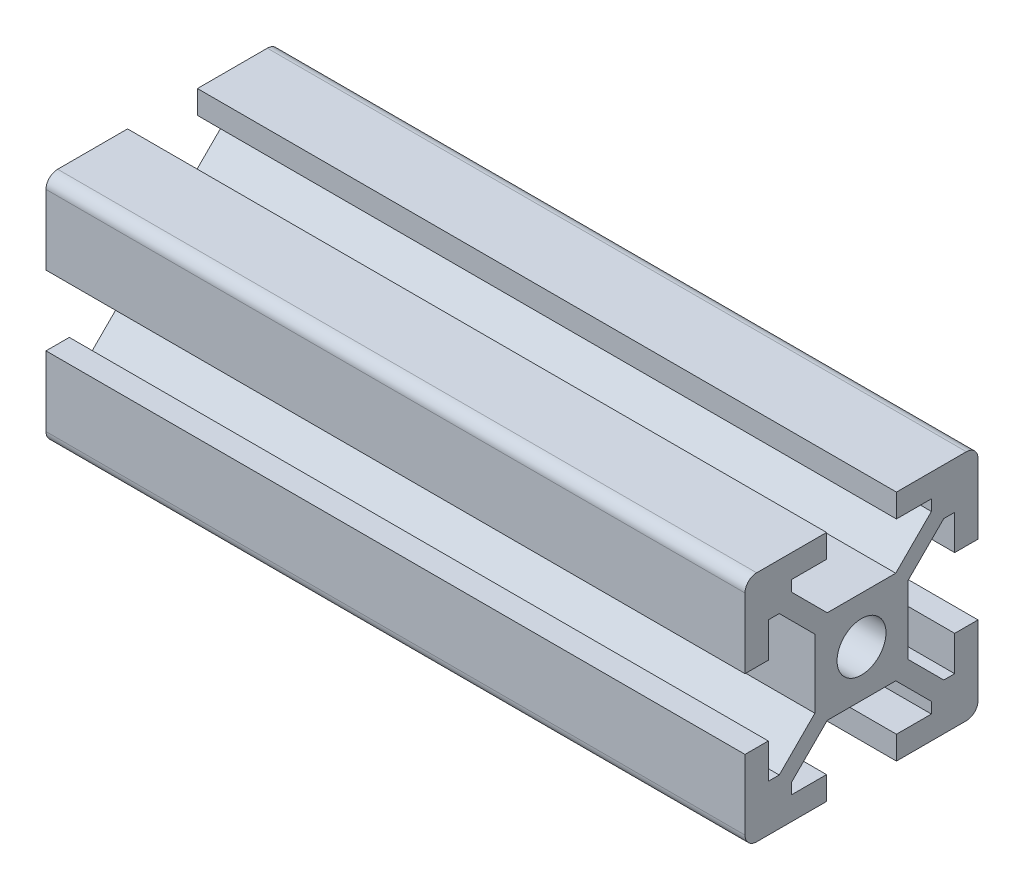
from build123d import *

# Parameters (mm, degrees)
SKETCH1_R           = 2.1
BOSS_EXTRUDE1_DEPTH = 60


with BuildPart() as part:
    # Sketch1 → Boss-Extrude1 (new body)
    with BuildSketch(Plane(origin=(0, 0, 0), x_dir=(0, 0, -1), z_dir=(1, 0, 0))):
        with BuildLine():
            Line((-10, 9), (-10, 3))
            Line((-10, 3), (-8, 3))
            Line((-8, 3), (-8, 6))
            Line((-8, 6), (-7.060660172, 6))
            Line((-7.060660172, 6), (-4, 2.939339828))
            Line((-4, 2.939339828), (-4, -2.939339828))
            Line((-4, -2.939339828), (-7.060660172, -6))
            Line((-7.060660172, -6), (-8, -6))
            Line((-8, -6), (-8, -3))
            Line((-8, -3), (-10, -3))
            Line((-10, -3), (-10, -9))
            ThreePointArc((-10, -9), (-9.707106781, -9.707106781), (-9, -10))
            Line((-9, -10), (-3, -10))
            Line((-3, -10), (-3, -8))
            Line((-3, -8), (-6, -8))
            Line((-6, -8), (-6, -7.060660172))
            Line((-6, -7.060660172), (-2.939339828, -4))
            Line((-2.939339828, -4), (2.939339828, -4))
            Line((2.939339828, -4), (6, -7.060660172))
            Line((6, -7.060660172), (6, -8))
            Line((6, -8), (3, -8))
            Line((3, -8), (3, -10))
            Line((3, -10), (9, -10))
            ThreePointArc((9, -10), (9.707106781, -9.707106781), (10, -9))
            Line((10, -9), (10, -3))
            Line((10, -3), (8, -3))
            Line((8, -3), (8, -6))
            Line((8, -6), (7.060660172, -6))
            Line((7.060660172, -6), (4, -2.939339828))
            Line((4, -2.939339828), (4, 2.939339828))
            Line((4, 2.939339828), (7.060660172, 6))
            Line((7.060660172, 6), (8, 6))
            Line((8, 6), (8, 3))
            Line((8, 3), (10, 3))
            Line((10, 3), (10, 9))
            ThreePointArc((10, 9), (9.707106781, 9.707106781), (9, 10))
            Line((9, 10), (3, 10))
            Line((3, 10), (3, 8))
            Line((3, 8), (6, 8))
            Line((6, 8), (6, 7.060660172))
            Line((6, 7.060660172), (2.939339828, 4))
            Line((2.939339828, 4), (-2.939339828, 4))
            Line((-2.939339828, 4), (-6, 7.060660172))
            Line((-6, 7.060660172), (-6, 8))
            Line((-6, 8), (-3, 8))
            Line((-3, 8), (-3, 10))
            Line((-3, 10), (-9, 10))
            ThreePointArc((-9, 10), (-9.707106781, 9.707106781), (-10, 9))
        make_face()
        Circle(SKETCH1_R, mode=Mode.SUBTRACT)
    extrude(amount=BOSS_EXTRUDE1_DEPTH)


solid = part.part
